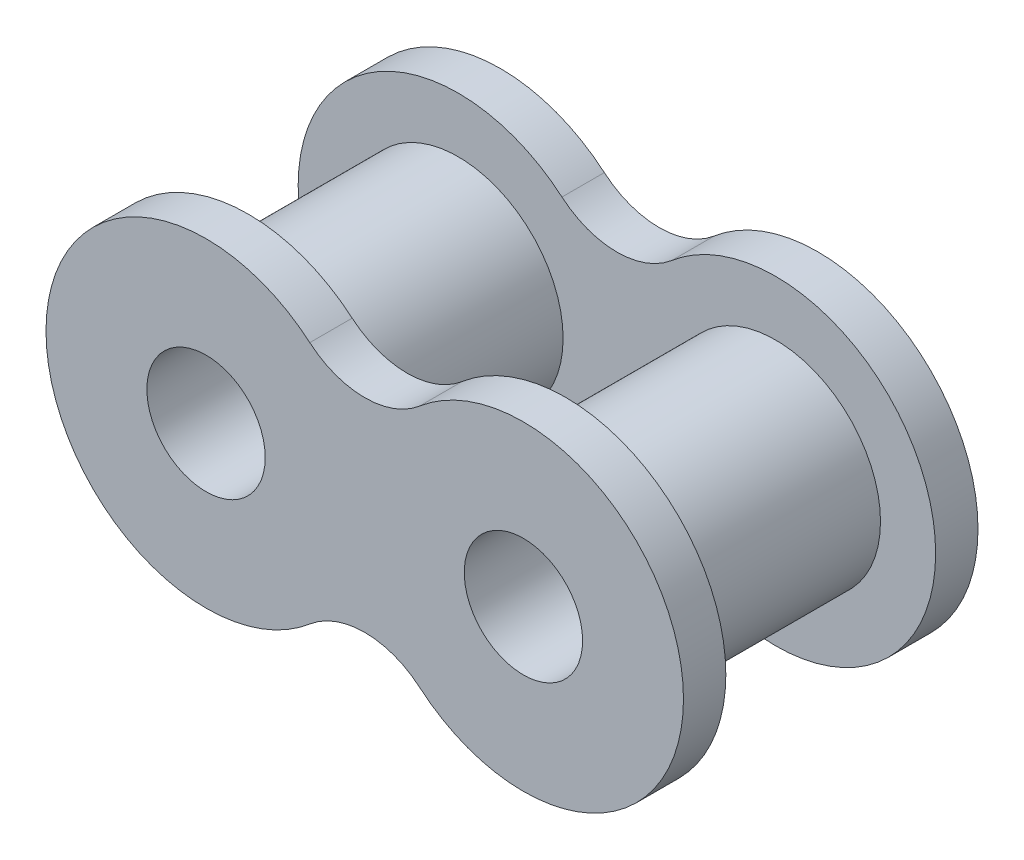
from build123d import *

# Parameters (mm, degrees)
SKETCH1_R             = 3.9624
SKETCH1_R_2           = 2.2352
BOSS_EXTRUDE1_DEPTH   = 5.5626
BOSS_EXTRUDE1_2_DEPTH = 5.5626
SKETCH2_R             = 3.9624
BOSS_EXTRUDE2_DEPTH   = 1.6002


with BuildPart() as part:
    # Sketch1 → Boss-Extrude1 (new body, symmetric)
    with BuildSketch(Plane.XY):
        with Locations((-5.9944, 0)):
            Circle(SKETCH1_R)
        with Locations((-5.9944, 0)):
            Circle(SKETCH1_R_2, mode=Mode.SUBTRACT)
    extrude(amount=BOSS_EXTRUDE1_DEPTH, both=True)



with BuildPart() as body_2:
    # Sketch1 → Boss-Extrude1 2 (new body, symmetric)
    with BuildSketch(Plane.XY):
        with Locations((5.9944, 0)):
            Circle(SKETCH1_R)
        with Locations((5.9944, 0)):
            Circle(SKETCH1_R_2, mode=Mode.SUBTRACT)
    extrude(amount=BOSS_EXTRUDE1_2_DEPTH, both=True)


with BuildPart() as part_1:
    add(part.part)

    add(body_2.part)  # Boss-Extrude2 merges body 2
    # Sketch2 → Boss-Extrude2 (add)
    with BuildSketch(Plane.XY.offset(5.5626)):
        with BuildLine():
            ThreePointArc((-2.074984615, 4.6024587), (-12.0396, 0), (-2.074984615, -4.6024587))
            ThreePointArc((-2.074984615, -4.6024587), (0, -3.838654482), (2.074984615, -4.6024587))
            ThreePointArc((2.074984615, -4.6024587), (12.0396, 0), (2.074984615, 4.6024587))
            ThreePointArc((2.074984615, 4.6024587), (0, 3.838654482), (-2.074984615, 4.6024587))
        make_face()
        with Locations((5.9944, 0)):
            Circle(SKETCH2_R, mode=Mode.SUBTRACT)
        with Locations((-5.9944, 0)):
            Circle(SKETCH2_R, mode=Mode.SUBTRACT)
    boss_extrude2 = extrude(amount=-BOSS_EXTRUDE2_DEPTH)

    # Mirror1: Boss-Extrude2 across plane
    add(boss_extrude2.mirror(Plane.XY))


solid = part_1.part
